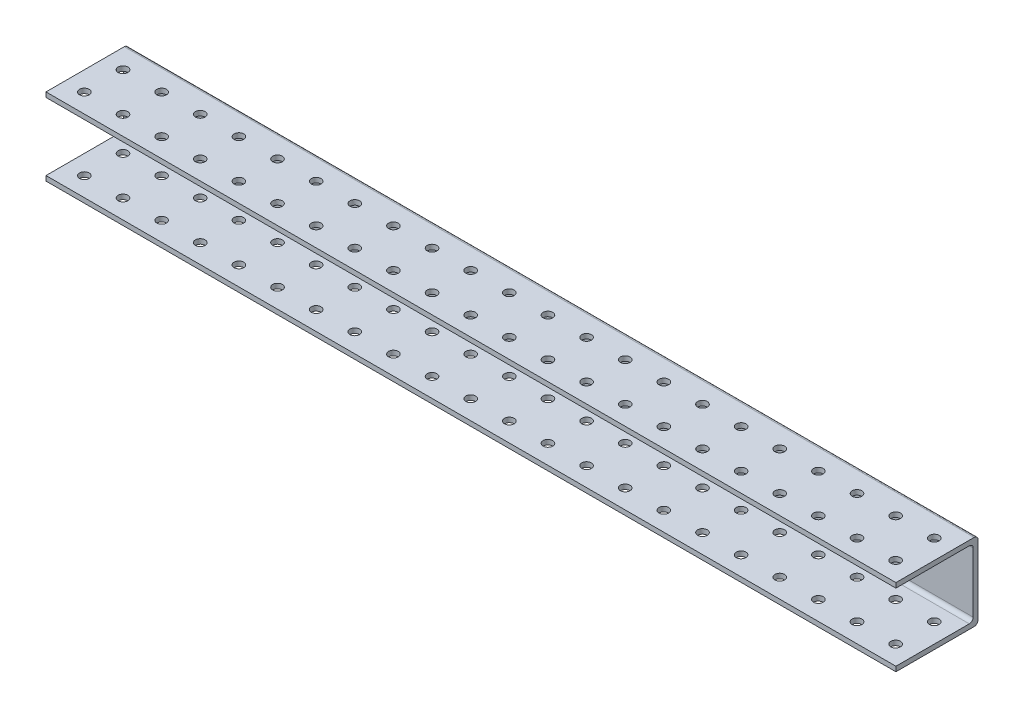
from build123d import *

# Parameters (mm, degrees)
SKETCH1_W           = 558.8
SKETCH1_H           = 38.1
BOSS_EXTRUDE1_DEPTH = 3.175
SKETCH2_W           = 558.8
SKETCH2_H           = 3.175
BOSS_EXTRUDE2_DEPTH = 44.45
FILLET1_R           = 2.54
SKETCH3_R           = 3.175
CUT_EXTRUDE1_DEPTH  = 44.45
CUT_EXTRUDE2_DEPTH  = 650.113
BOSS_EXTRUDE3_DEPTH = 558.8
SKETCH6_W           = 32.897959938
SKETCH6_H           = 44.45
CUT_EXTRUDE3_DEPTH  = 558.8
FILLET2_R           = 2.54


with BuildPart() as part:
    # Sketch1 → Boss-Extrude1 (new body)
    with BuildSketch(Plane.XY):
        with Locations((279.4, 19.05)):
            Rectangle(SKETCH1_W, SKETCH1_H)
    extrude(amount=BOSS_EXTRUDE1_DEPTH)

    # Sketch2 → Boss-Extrude2 (add)
    with BuildSketch(Plane.XY.offset(3.175)):
        with Locations((279.4, 36.5125)):
            Rectangle(SKETCH2_W, SKETCH2_H)
        with Locations((279.4, 1.5875)):
            Rectangle(SKETCH2_W, SKETCH2_H)
    extrude(amount=BOSS_EXTRUDE2_DEPTH)

    # Fillet1
    fillet1_edges = [part.edges().sort_by_distance(p)[0] for p in [
        (279.4, 34.925, 3.175),
        (279.4, 3.175, 3.175),
        (279.4, 0, 0),
        (279.4, 38.1, 0),
    ]]
    fillet(fillet1_edges, radius=FILLET1_R)

    # Sketch3 → Cut-Extrude1 (cut)
    with BuildSketch(Plane(origin=(0, 38.1, 0), x_dir=(1, 0, 0), z_dir=(0, 1, 0))):
        with Locations((12.7, -35.1028)):
            Circle(SKETCH3_R)
        with Locations((38.1, -35.1028)):
            Circle(SKETCH3_R)
        with Locations((63.5, -35.1028)):
            Circle(SKETCH3_R)
        with Locations((88.9, -35.1028)):
            Circle(SKETCH3_R)
        with Locations((114.3, -35.1028)):
            Circle(SKETCH3_R)
        with Locations((139.7, -35.1028)):
            Circle(SKETCH3_R)
        with Locations((165.1, -35.1028)):
            Circle(SKETCH3_R)
        with Locations((190.5, -35.1028)):
            Circle(SKETCH3_R)
        with Locations((215.9, -35.1028)):
            Circle(SKETCH3_R)
        with Locations((241.3, -35.1028)):
            Circle(SKETCH3_R)
        with Locations((266.7, -35.1028)):
            Circle(SKETCH3_R)
        with Locations((292.1, -35.1028)):
            Circle(SKETCH3_R)
        with Locations((317.5, -35.1028)):
            Circle(SKETCH3_R)
        with Locations((342.9, -35.1028)):
            Circle(SKETCH3_R)
        with Locations((368.3, -35.1028)):
            Circle(SKETCH3_R)
        with Locations((393.7, -35.1028)):
            Circle(SKETCH3_R)
        with Locations((419.1, -35.1028)):
            Circle(SKETCH3_R)
        with Locations((444.5, -35.1028)):
            Circle(SKETCH3_R)
        with Locations((469.9, -35.1028)):
            Circle(SKETCH3_R)
        with Locations((495.3, -35.1028)):
            Circle(SKETCH3_R)
        with Locations((520.7, -35.1028)):
            Circle(SKETCH3_R)
        with Locations((546.1, -35.1028)):
            Circle(SKETCH3_R)
        with Locations((38.1, -9.7028)):
            Circle(SKETCH3_R)
        with Locations((63.5, -9.7028)):
            Circle(SKETCH3_R)
        with Locations((88.9, -9.7028)):
            Circle(SKETCH3_R)
        with Locations((114.3, -9.7028)):
            Circle(SKETCH3_R)
        with Locations((139.7, -9.7028)):
            Circle(SKETCH3_R)
        with Locations((165.1, -9.7028)):
            Circle(SKETCH3_R)
        with Locations((190.5, -9.7028)):
            Circle(SKETCH3_R)
        with Locations((215.9, -9.7028)):
            Circle(SKETCH3_R)
        with Locations((241.3, -9.7028)):
            Circle(SKETCH3_R)
        with Locations((266.7, -9.7028)):
            Circle(SKETCH3_R)
        with Locations((292.1, -9.7028)):
            Circle(SKETCH3_R)
        with Locations((317.5, -9.7028)):
            Circle(SKETCH3_R)
        with Locations((342.9, -9.7028)):
            Circle(SKETCH3_R)
        with Locations((368.3, -9.7028)):
            Circle(SKETCH3_R)
        with Locations((393.7, -9.7028)):
            Circle(SKETCH3_R)
        with Locations((419.1, -9.7028)):
            Circle(SKETCH3_R)
        with Locations((444.5, -9.7028)):
            Circle(SKETCH3_R)
        with Locations((469.9, -9.7028)):
            Circle(SKETCH3_R)
        with Locations((495.3, -9.7028)):
            Circle(SKETCH3_R)
        with Locations((520.7, -9.7028)):
            Circle(SKETCH3_R)
        with Locations((546.1, -9.7028)):
            Circle(SKETCH3_R)
        with Locations((12.7, -9.7028)):
            Circle(SKETCH3_R)
    extrude(amount=-CUT_EXTRUDE1_DEPTH, mode=Mode.SUBTRACT)

    # Sketch4 → Cut-Extrude2 (cut)
    with BuildSketch(Plane(origin=(558.8, 0, 0), x_dir=(0, 0, -1), z_dir=(1, 0, 0))):
        Polygon((-2.54, 25.4), (13.885485297, 25.4), (13.885485297, 51.082453825), (-54.332543736, 51.082453825), (-54.332543736, 25.4), align=None)
    extrude(amount=-CUT_EXTRUDE2_DEPTH, mode=Mode.SUBTRACT)

    # Mirror1: part across plane


with BuildPart() as part_1:
    add(part.part)
    add(part.part.mirror(Plane(origin=(-91.313, 25.4, 2.54), x_dir=(0, 0, 1), z_dir=(0, -1, 0))))

    # Sketch5 → Boss-Extrude3 (add)
    with BuildSketch(Plane(origin=(558.8, 0, 0), x_dir=(0, 0, -1), z_dir=(1, 0, 0))):
        with BuildLine():
            Line((3.175, 50.8), (-2.54, 50.8))
            ThreePointArc((-2.54, 50.8), (-0.743948776, 50.056051224), (0, 48.26))
            Line((0, 48.26), (0, 47.625))
            Line((0, 47.625), (3.175, 47.625))
            Line((3.175, 47.625), (3.175, 50.8))
        make_face()
        with BuildLine():
            Line((-2.54, 50.8), (-3.966383497, 50.8))
            Line((-3.966383497, 50.8), (-3.966383497, 47.625))
            Line((-3.966383497, 47.625), (0, 47.625))
            Line((0, 47.625), (0, 48.26))
            ThreePointArc((0, 48.26), (-0.743948776, 50.056051224), (-2.54, 50.8))
        make_face()
        Polygon((6.35, 50.8), (3.175, 50.8), (3.175, 47.625), (3.175, 3.175), (3.175, 0), (6.35, 0), align=None)
        with BuildLine():
            ThreePointArc((0, 2.54), (-0.743948776, 0.743948776), (-2.54, 0))
            Line((-2.54, 0), (3.175, 0))
            Line((3.175, 0), (3.175, 3.175))
            Line((3.175, 3.175), (0, 3.175))
            Line((0, 3.175), (0, 2.54))
        make_face()
        with BuildLine():
            Line((-5.715, 3.175), (-5.715, 0))
            Line((-5.715, 0), (-2.54, 0))
            ThreePointArc((-2.54, 0), (-0.743948776, 0.743948776), (0, 2.54))
            Line((0, 2.54), (0, 3.175))
            Line((0, 3.175), (-5.715, 3.175))
        make_face()
    extrude(amount=-BOSS_EXTRUDE3_DEPTH)

    # Sketch6 → Cut-Extrude3 (cut)
    with BuildSketch(Plane(origin=(558.8, 0, 0), x_dir=(0, 0, -1), z_dir=(1, 0, 0))):
        with Locations((-13.273979969, 25.4)):
            Rectangle(SKETCH6_W, SKETCH6_H)
    extrude(amount=-CUT_EXTRUDE3_DEPTH, mode=Mode.SUBTRACT)

    # Fillet2
    fillet2_edges = [part_1.edges().sort_by_distance(p)[0] for p in [
        (279.4, 0, -6.35),
        (279.4, 3.175, -3.175),
        (279.4, 47.625, -3.175),
        (279.4, 50.8, -6.35),
    ]]
    fillet(fillet2_edges, radius=FILLET2_R)


solid = part_1.part
